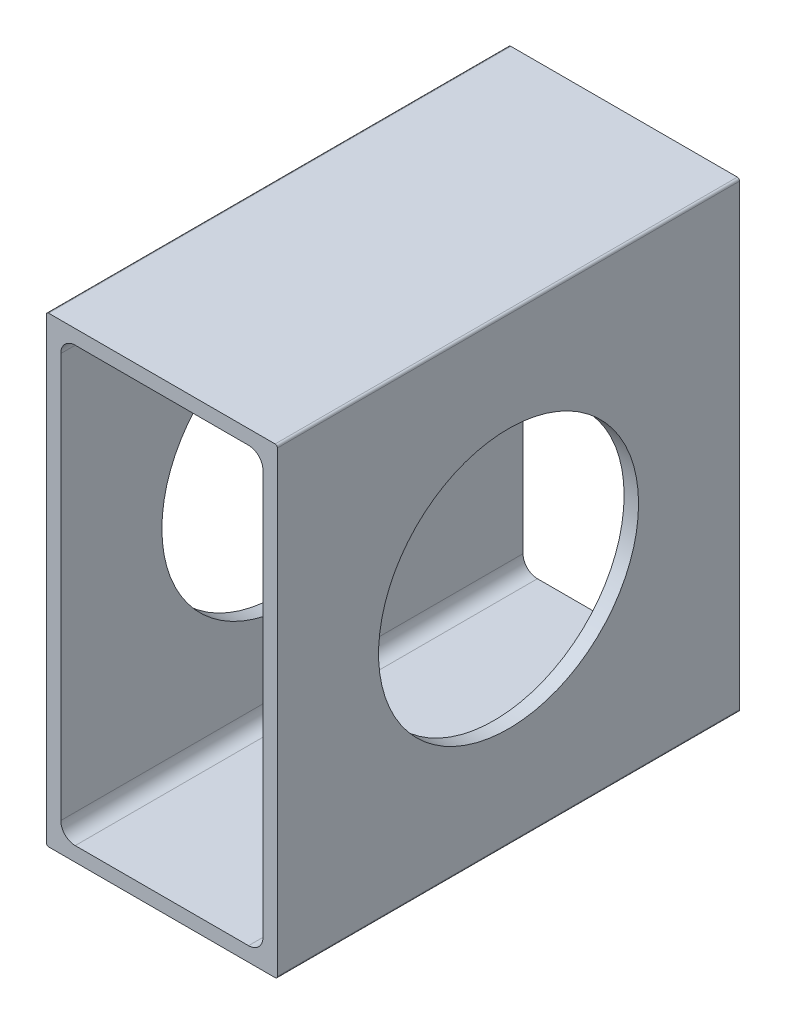
from build123d import *

# Parameters (mm, degrees)
BOSS_EXTRUDE1_DEPTH = 50.8
SKETCH2_R           = 14.2875
CUT_EXTRUDE1_DEPTH  = 50.8


with BuildPart() as part:
    # Sketch1 → Boss-Extrude1 (new body)
    with BuildSketch(Plane(origin=(0, 0, 0), x_dir=(-1, 0, 0), z_dir=(0, 0, -1))):
        with BuildLine():
            Line((-12.7, 25.146), (-12.7, -25.146))
            ThreePointArc((-12.7, -25.146), (-12.625605122, -25.325605122), (-12.446, -25.4))
            Line((-12.446, -25.4), (12.446, -25.4))
            ThreePointArc((12.446, -25.4), (12.625605122, -25.325605122), (12.7, -25.146))
            Line((12.7, -25.146), (12.7, 25.146))
            ThreePointArc((12.7, 25.146), (12.625605122, 25.325605122), (12.446, 25.4))
            Line((12.446, 25.4), (-12.446, 25.4))
            ThreePointArc((-12.446, 25.4), (-12.625605122, 25.325605122), (-12.7, 25.146))
        make_face()
        with BuildLine():
            Line((-11.1125, -22.225), (-11.1125, 22.225))
            ThreePointArc((-11.1125, 22.225), (-10.647532015, 23.347532015), (-9.525, 23.8125))
            Line((-9.525, 23.8125), (9.525, 23.8125))
            ThreePointArc((9.525, 23.8125), (10.647532015, 23.347532015), (11.1125, 22.225))
            Line((11.1125, 22.225), (11.1125, -22.225))
            ThreePointArc((11.1125, -22.225), (10.647532015, -23.347532015), (9.525, -23.8125))
            Line((9.525, -23.8125), (-9.525, -23.8125))
            ThreePointArc((-9.525, -23.8125), (-10.647532015, -23.347532015), (-11.1125, -22.225))
        make_face(mode=Mode.SUBTRACT)
    extrude(amount=-BOSS_EXTRUDE1_DEPTH)

    # Sketch2 → Cut-Extrude1 (cut)
    with BuildSketch(Plane.ZY.offset(12.7)):
        with Locations((25.4, 0)):
            Circle(SKETCH2_R)
    extrude(amount=-CUT_EXTRUDE1_DEPTH, mode=Mode.SUBTRACT)


solid = part.part
